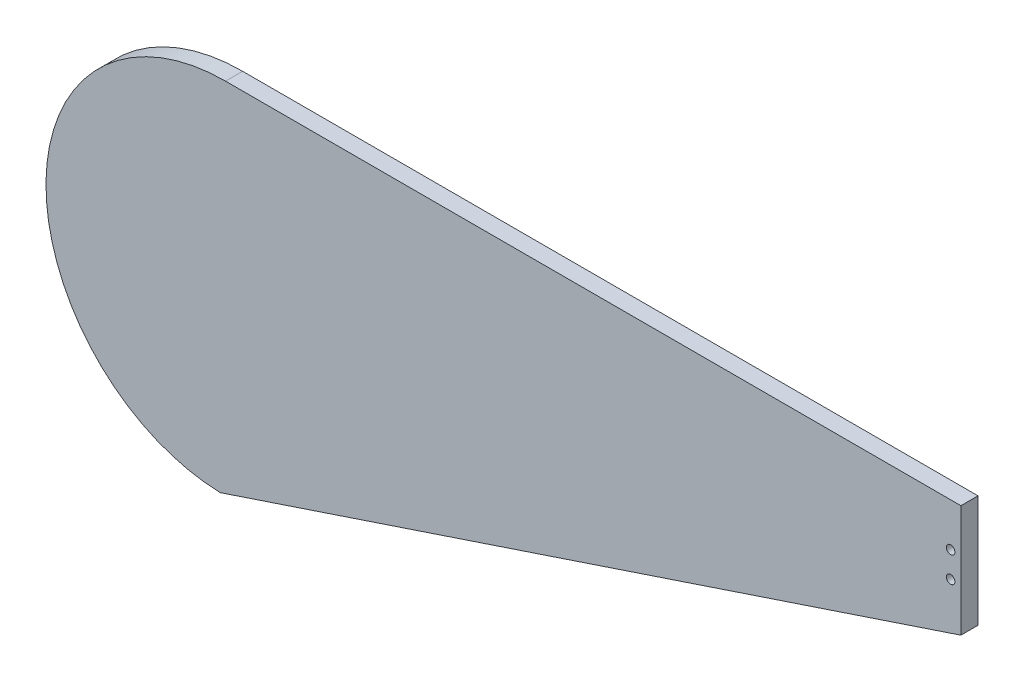
from build123d import *

# Parameters (mm, degrees)
BOSS_EXTRUDE1_DEPTH = 10
SKETCH2_R           = 2.5
CUT_EXTRUDE1_DEPTH  = 11


with BuildPart() as part:
    # Sketch1 → Boss-Extrude1 (new body)
    with BuildSketch(Plane.XY):
        with BuildLine():
            Line((0, 105), (430, 105))
            Line((430, 105), (430, 39.415184401))
            Line((430, 39.415184401), (-3.107566291, -104.954004363))
            ThreePointArc((-3.107566291, -104.954004363), (-104.988500461, 1.553953334), (0, 105))
        make_face()
    extrude(amount=BOSS_EXTRUDE1_DEPTH)

    # Sketch2 → Cut-Extrude1 (cut, through all)
    with BuildSketch(Plane.XY.offset(10)):
        with Locations((424, 79.707592201)):
            Circle(SKETCH2_R)
        with Locations((424, 64.707592201)):
            Circle(SKETCH2_R)
    extrude(amount=-CUT_EXTRUDE1_DEPTH, mode=Mode.SUBTRACT)


solid = part.part
